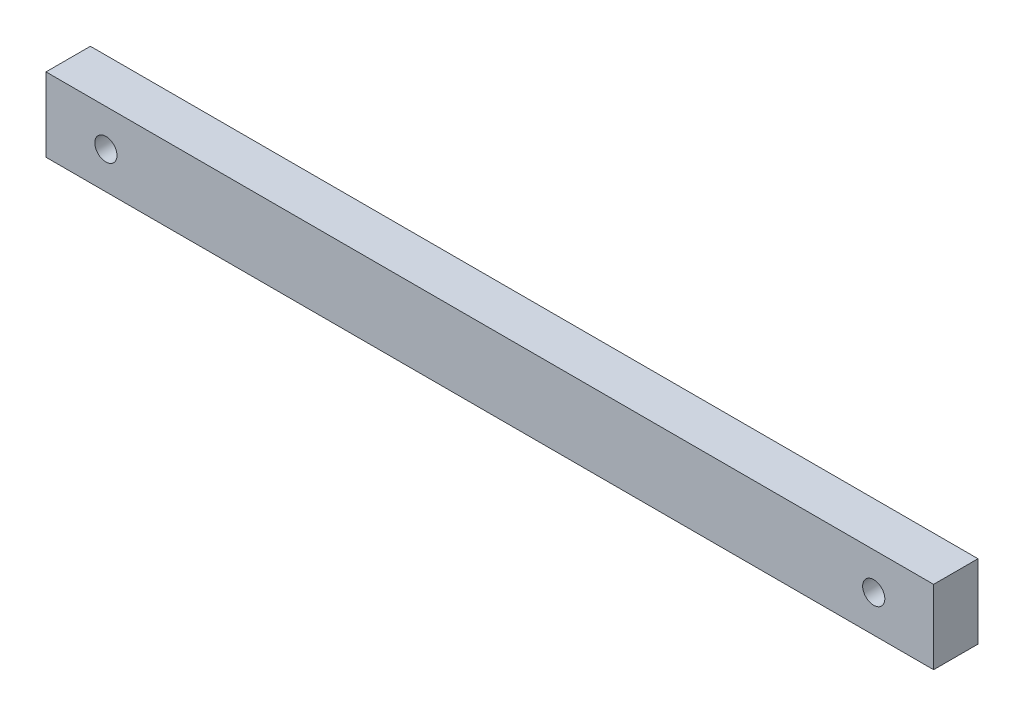
from build123d import *

# Parameters (mm, degrees)
SKETCH_1_W          = 120
SKETCH_1_H          = 10
EXTRUDE_1_DEPTH     = 6
SKETCH_2_R          = 1.5
CUT_EXTRUDE_1_DEPTH = 7


with BuildPart() as part:
    # 草图1 → 凸台-拉伸1 (new body)
    with BuildSketch(Plane.XY):
        with Locations((-4.208416834, 15.320641283)):
            Rectangle(SKETCH_1_W, SKETCH_1_H)
    extrude(amount=EXTRUDE_1_DEPTH)

    # 草图2 → 切除-拉伸1 (cut, through all)
    with BuildSketch(Plane.XY.offset(6)):
        with Locations((-56.112630763, 15.320641283)):
            Circle(SKETCH_2_R)
        with Locations((47.695797096, 15.320641283)):
            Circle(SKETCH_2_R)
    extrude(amount=-CUT_EXTRUDE_1_DEPTH, mode=Mode.SUBTRACT)


solid = part.part
